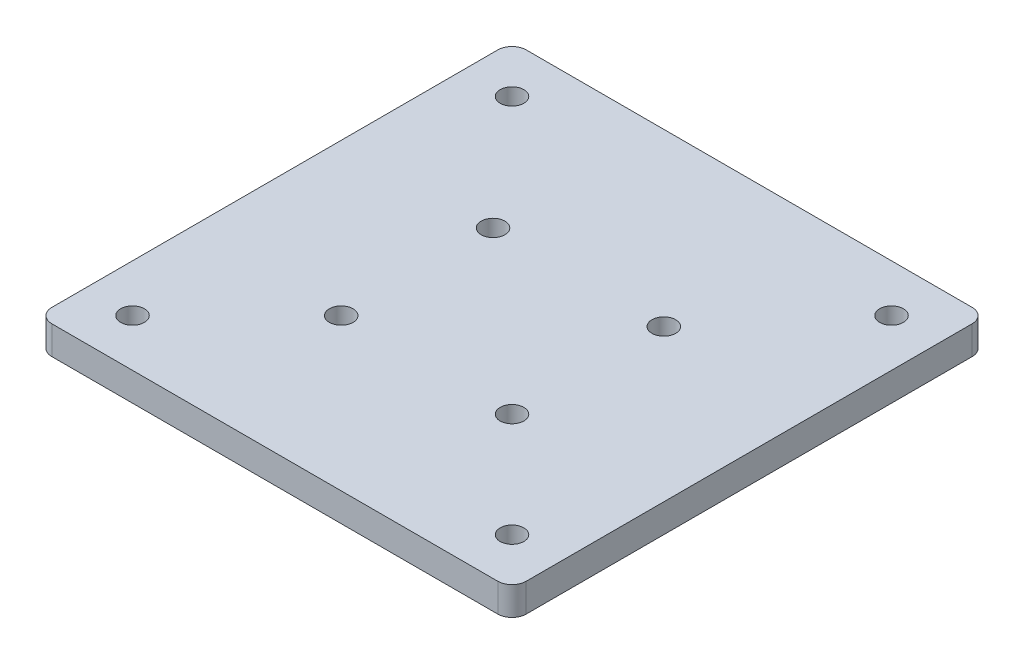
from build123d import *

# Parameters (mm, degrees)
SKETCH1_W           = 100
SKETCH1_H           = 100
SKETCH1_R           = 2.5
BOSS_EXTRUDE1_DEPTH = 6
FILLET1_R           = 3
FILLET2_R           = 3
SCALE1_SCALE        = 7.5


with BuildPart() as part:
    # Sketch1 → Boss-Extrude1 (new body)
    with BuildSketch(Plane(origin=(0, 0, 0), x_dir=(1, 0, 0), z_dir=(0, 1, 0))):
        with Locations((40, 40)):
            Rectangle(SKETCH1_W, SKETCH1_H)
        Circle(SKETCH1_R, mode=Mode.SUBTRACT)
        with Locations((80, 0)):
            Circle(SKETCH1_R, mode=Mode.SUBTRACT)
        with Locations((0, 80)):
            Circle(SKETCH1_R, mode=Mode.SUBTRACT)
        with Locations((80, 80)):
            Circle(SKETCH1_R, mode=Mode.SUBTRACT)
        with Locations((22, 22)):
            Circle(SKETCH1_R, mode=Mode.SUBTRACT)
        with Locations((58, 22)):
            Circle(SKETCH1_R, mode=Mode.SUBTRACT)
        with Locations((22, 54)):
            Circle(SKETCH1_R, mode=Mode.SUBTRACT)
        with Locations((58, 54)):
            Circle(SKETCH1_R, mode=Mode.SUBTRACT)
    extrude(amount=BOSS_EXTRUDE1_DEPTH)

    # Fillet1
    fillet1_edges = [part.edges().sort_by_distance(p)[0] for p in [
        (90, 3, 10),
        (-10, 3, 10),
    ]]
    fillet(fillet1_edges, radius=FILLET1_R)

    # Fillet2
    fillet2_edges = [part.edges().sort_by_distance(p)[0] for p in [
        (-10, 3, -90),
        (90, 3, -90),
    ]]
    fillet(fillet2_edges, radius=FILLET2_R)


with BuildPart() as part_1:
    # Scale1: scaled about (40, 3, -40.015971177)
    add(part.part.scale(SCALE1_SCALE).moved(Location((-260, -19.5, 260.103812651))))


solid = part_1.part
